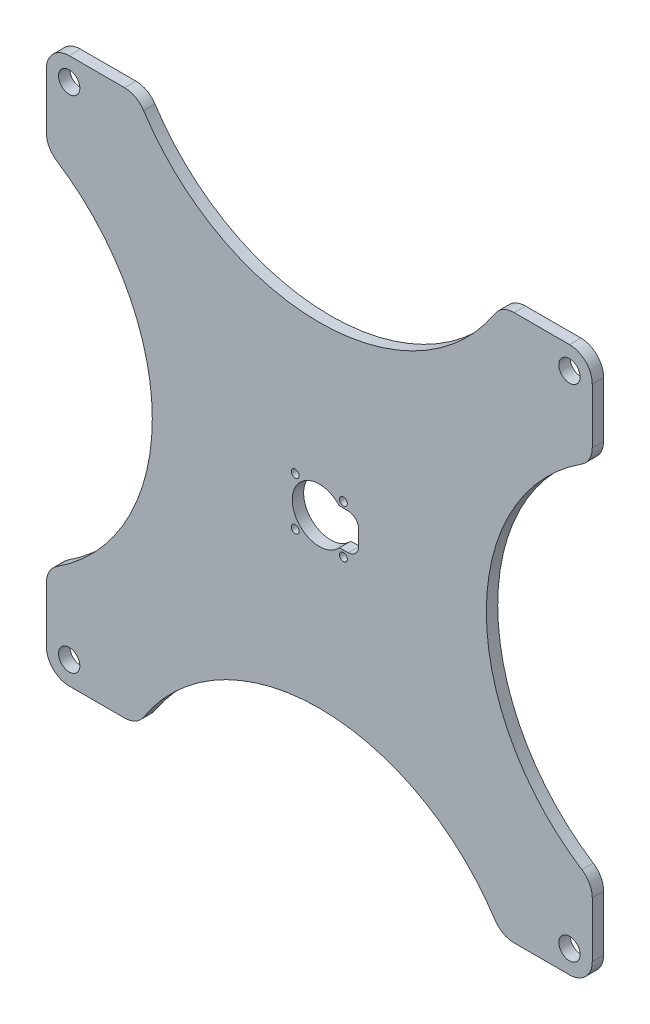
from build123d import *

# Parameters (mm, degrees)
SKETCH3_W               = 152.4
SKETCH3_H               = 152.4
BOSS_EXTRUDE3_DEPTH     = 3.175
MOTOR_CUT_OUT_DEPTH     = 4.175
SKETCH20_R              = 2.9718
BOLT_HOLES_DEPTH        = 1
BOLT_HOLES_DEPTH_BACK   = 4.175
EDGE_CUT_OUT_DEPTH      = 3.175
FILLET2_R               = 6.35
MIRROR5_COPY_1_DEPTH    = 3.175
FILLET3_R               = 6.35
FILLET4_R               = 6.35
FILLET12_R              = 3
SKETCH27_R              = 1.1
MOTOR_SCREWS_HOLE_DEPTH = 4.175


with BuildPart() as part:
    # Sketch3 → Boss-Extrude3 (new body)
    with BuildSketch(Plane.XY):
        Rectangle(SKETCH3_W, SKETCH3_H)
    extrude(amount=BOSS_EXTRUDE3_DEPTH)

    # Sketch13 → Motor Cut Out (cut, through all)
    with BuildSketch(Plane(origin=(0.106889783, -2.03090588, 3.175), x_dir=(1, 0, 0), z_dir=(0, 0, 1))):
        with BuildLine():
            Line((5.483280161, 7.105597989), (10.893110217, 7.105597989))
            Line((10.893110217, 7.105597989), (10.893110217, -2.894402011))
            Line((10.893110217, -2.894402011), (5.483280161, -3.043786229))
            ThreePointArc((5.483280161, -3.043786229), (-7.656889783, 2.03090588), (5.483280161, 7.105597989))
        make_face()
    extrude(amount=-MOTOR_CUT_OUT_DEPTH, mode=Mode.SUBTRACT)

    # Sketch20 → Bolt Holes (cut, two sides)
    with BuildSketch(Plane.XY.offset(3.175)) as bolt_holes_sk:
        with Locations((-69.83, 69.83)):
            Circle(SKETCH20_R)
        with Locations((69.83, 69.83)):
            Circle(SKETCH20_R)
        with Locations((69.83, -69.83)):
            Circle(SKETCH20_R)
        with Locations((-69.83, -69.83)):
            Circle(SKETCH20_R)
    extrude(amount=BOLT_HOLES_DEPTH, mode=Mode.SUBTRACT)
    extrude(bolt_holes_sk.sketch, amount=-BOLT_HOLES_DEPTH_BACK, mode=Mode.SUBTRACT)

    # Sketch25 → Edge cut out (cut)
    with BuildSketch(Plane.XY.offset(3.175)):
        with BuildLine():
            Line((-76.2, 50.8), (-76.2, -50.8))
            ThreePointArc((-76.2, -50.8), (-46.628854397, 0), (-76.2, 50.8))
        make_face()
    edge_cut_out = extrude(amount=-EDGE_CUT_OUT_DEPTH, mode=Mode.SUBTRACT)

    # Fillet2
    fillet2_edges = [part.edges().sort_by_distance(p)[0] for p in [
        (-76.2, -50.8, 1.5875),
        (-76.2, 50.8, 1.5875),
        (-76.2, -76.2, 1.5875),
        (-76.2, 76.2, 1.5875),
    ]]
    fillet(fillet2_edges, radius=FILLET2_R)

    # Mirror4: Edge cut out across plane
    add(edge_cut_out.mirror(Plane(origin=(0, 0, 0), x_dir=(0, 0, 1), z_dir=(0.707106781, -0.707106781, 0))), mode=Mode.SUBTRACT)

    # Mirror5: Edge cut out across plane
    add(edge_cut_out.mirror(Plane(origin=(0, 0, 0), x_dir=(0, 0, 1), z_dir=(-0.707106781, -0.707106781, 0))), mode=Mode.SUBTRACT)

    # Mirror5 copy 1 sketch → Mirror5 copy 1 (cut)
    with BuildSketch(Plane(origin=(0, 0, 3.175), x_dir=(-1, 0, 0), z_dir=(0, 0, 1))):
        with BuildLine():
            Line((-76.2, 50.8), (-76.2, -50.8))
            ThreePointArc((-76.2, -50.8), (-46.628854397, 0), (-76.2, 50.8))
        make_face()
    extrude(amount=-MIRROR5_COPY_1_DEPTH, mode=Mode.SUBTRACT)

    # Fillet3
    fillet3_edges = [part.edges().sort_by_distance(p)[0] for p in [
        (76.2, -76.2, 1.5875),
        (76.2, 76.2, 1.5875),
        (-50.8, -76.2, 1.5875),
        (50.8, -76.2, 1.5875),
        (76.2, 50.8, 1.5875),
        (76.2, -50.8, 1.5875),
    ]]
    fillet(fillet3_edges, radius=FILLET3_R)

    # Fillet4
    fillet4_edges = [part.edges().sort_by_distance(p)[0] for p in [
        (50.8, 76.2, 1.5875),
        (-50.8, 76.2, 1.5875),
    ]]
    fillet(fillet4_edges, radius=FILLET4_R)

    # Fillet12
    fillet12_edges = [part.edges().sort_by_distance(p)[0] for p in [
        (11, 5.074692109, 1.5875),
        (11, -4.925307891, 1.5875),
    ]]
    fillet(fillet12_edges, radius=FILLET12_R)

    # Sketch27 → Motor screws hole (cut, through all)
    with BuildSketch(Plane.XY.offset(3.175)):
        with Locations((6.72, -6.72)):
            Circle(SKETCH27_R)
        with Locations((6.72, 6.72)):
            Circle(SKETCH27_R)
        with Locations((-6.72, 6.72)):
            Circle(SKETCH27_R)
        with Locations((-6.72, -6.72)):
            Circle(SKETCH27_R)
    extrude(amount=-MOTOR_SCREWS_HOLE_DEPTH, mode=Mode.SUBTRACT)


solid = part.part
